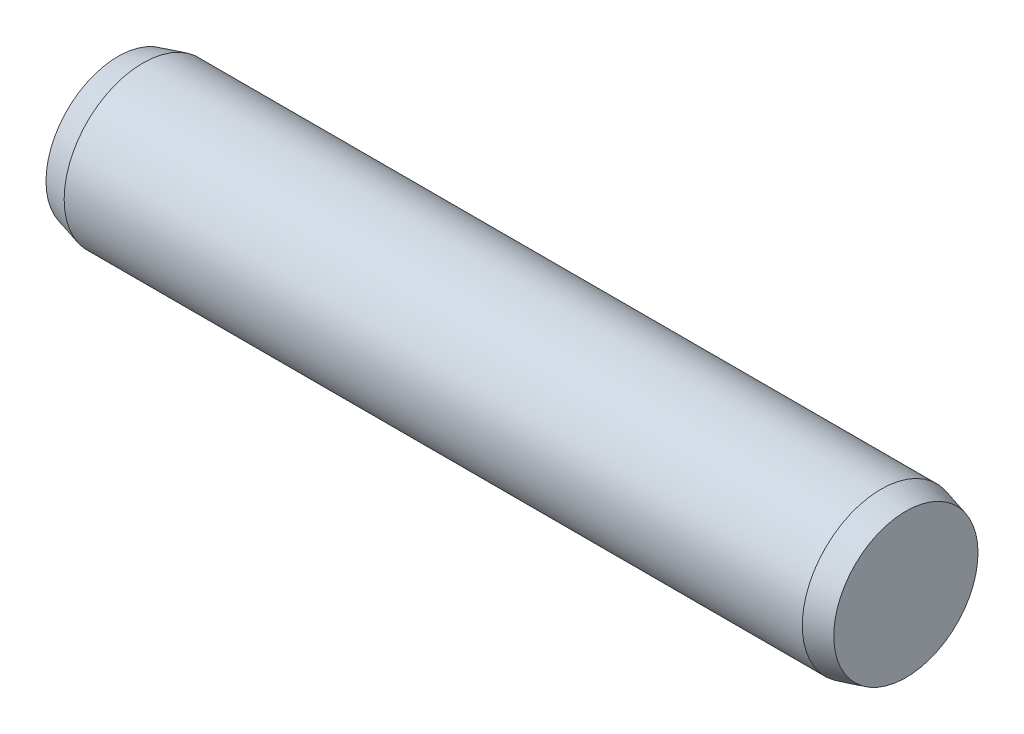
from build123d import *

# Parameters (mm, degrees)
SKETCH2_R           = 2
EXTRUDE1_DEPTH      = 9.37
EXTRUDE1_DEPTH_BACK = 9.37
SKETCH3_R           = 2
EXTRUDE2_DEPTH      = 0.63
EXTRUDE2_TAPER      = 15
SKETCH4_R           = 2
EXTRUDE3_DEPTH      = 0.63
EXTRUDE3_TAPER      = 15


with BuildPart() as part:
    # Sketch2 → Extrude1 (new body, two sides)
    with BuildSketch(Plane(origin=(0, 0, 0), x_dir=(0, 0, -1), z_dir=(1, 0, 0))) as extrude1_sk:
        Circle(SKETCH2_R)
    extrude(amount=EXTRUDE1_DEPTH)
    extrude(extrude1_sk.sketch, amount=-EXTRUDE1_DEPTH_BACK)

    # Sketch3 → Extrude2 (add)
    with BuildSketch(Plane(origin=(9.37, 0, 0), x_dir=(0, 0, -1), z_dir=(1, 0, 0))):
        Circle(SKETCH3_R)
    extrude(amount=EXTRUDE2_DEPTH, taper=EXTRUDE2_TAPER)

    # Sketch4 → Extrude3 (add)
    with BuildSketch(Plane.ZY.offset(9.37)):
        Circle(SKETCH4_R)
    extrude(amount=EXTRUDE3_DEPTH, taper=EXTRUDE3_TAPER)


solid = part.part
